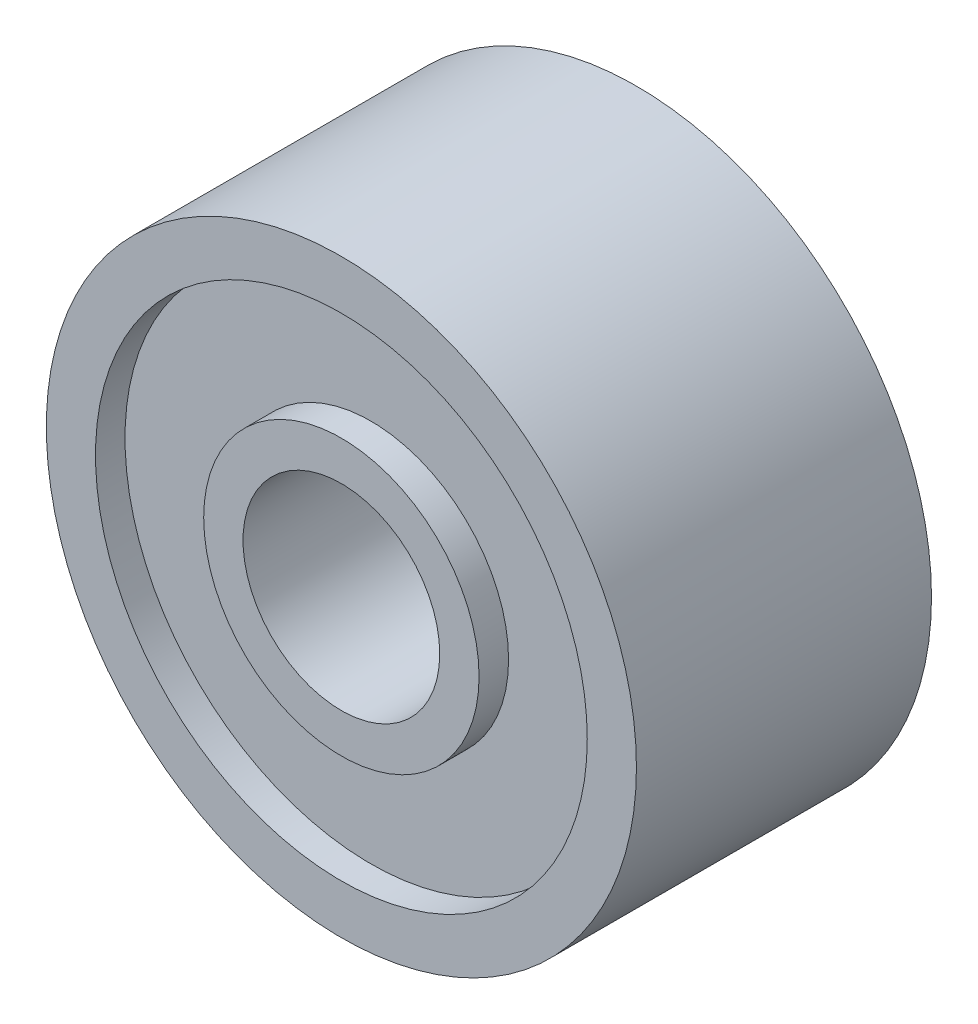
from build123d import *

# Parameters (mm, degrees)
SKETCH1_R           = 3
SKETCH1_R_2         = 1
BOSS_EXTRUDE1_DEPTH = 3
SKETCH2_R           = 2.5
SKETCH2_R_2         = 1.4
CUT_EXTRUDE1_DEPTH  = 0.3
CUT_EXTRUDE2_START  = -3
SKETCH2_2_R         = 2.5
SKETCH2_2_R_2       = 1.4
CUT_EXTRUDE2_DEPTH  = 0.3


with BuildPart() as part:
    # Sketch1 → Boss-Extrude1 (new body)
    with BuildSketch(Plane.XY):
        Circle(SKETCH1_R)
        Circle(SKETCH1_R_2, mode=Mode.SUBTRACT)
    extrude(amount=BOSS_EXTRUDE1_DEPTH)

    # Sketch2 → Cut-Extrude1 (cut)
    with BuildSketch(Plane.XY.offset(3)):
        Circle(SKETCH2_R)
        Circle(SKETCH2_R_2, mode=Mode.SUBTRACT)
    extrude(amount=-CUT_EXTRUDE1_DEPTH, mode=Mode.SUBTRACT)

    # Sketch2_2 → Cut-Extrude2 (cut)
    with BuildSketch(Plane.XY.offset(3).offset(CUT_EXTRUDE2_START)):
        Circle(SKETCH2_2_R)
        Circle(SKETCH2_2_R_2, mode=Mode.SUBTRACT)
    extrude(amount=CUT_EXTRUDE2_DEPTH, mode=Mode.SUBTRACT)


solid = part.part
